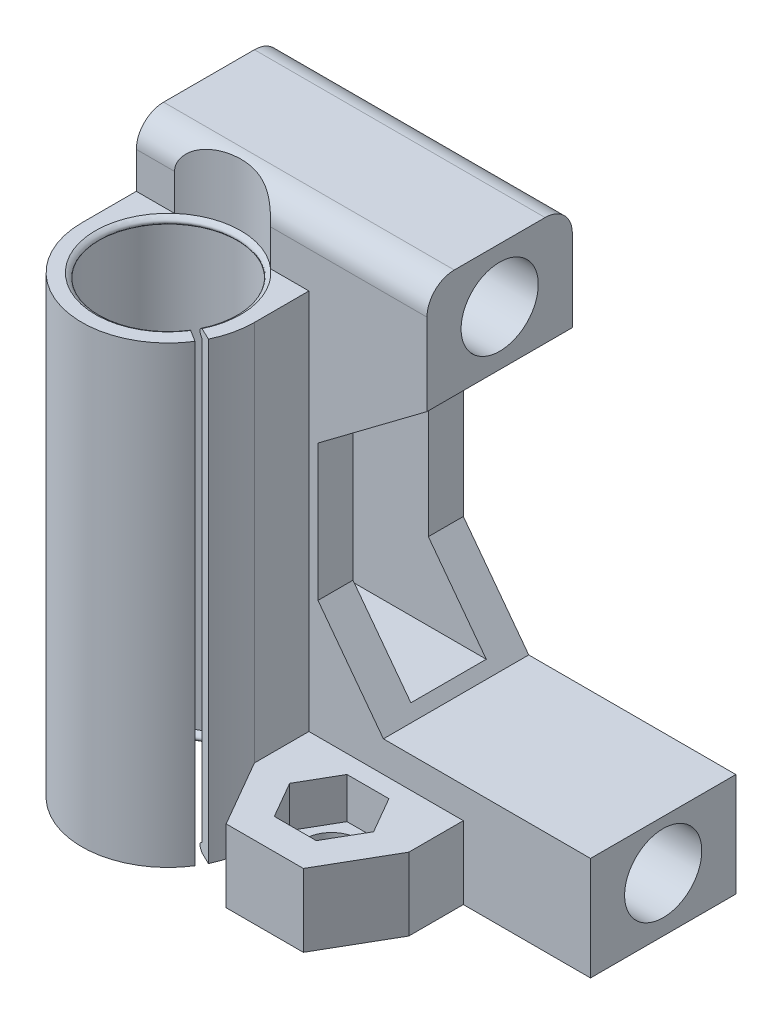
from build123d import *

# Parameters (mm, degrees)
BOSS_EXTRU_1_DEPTH           = 16
CONG_1_R                     = 3
ESQUISSE2_R                  = 4.25
ENL_V_MAT_EXTRU_1_DEPTH      = 78.491935064
BOSS_EXTRU_3_DEPTH           = 50
ENL_V_MAT_EXTRU_3_DEPTH      = 78.409624725
ENL_V_MAT_EXTRU_3_DEPTH_BACK = 78.409624725
BOSS_EXTRU_4_DEPTH           = 8
ENL_V_MAT_EXTRU_5_DEPTH      = 4.5
ESQUISSE10_R                 = 3
ENL_V_MAT_EXTRU_6_DEPTH      = 80.71511783


with BuildPart() as part:
    # Esquisse1 → Boss.-Extru.1 (new body)
    with BuildSketch(Plane.XY):
        Polygon((0, 0), (0, 57), (32, 57), (32, 45), (20, 36), (20, 21), (27.2, 11.4), (50, 11.4), (50, 0), align=None)
    extrude(amount=BOSS_EXTRU_1_DEPTH)

    # Congé1
    cong_1_edges = [part.edges().sort_by_distance(p)[0] for p in [
        (16, 57, 16),
        (16, 57, 0),
    ]]
    fillet(cong_1_edges, radius=CONG_1_R)

    # Esquisse2 → Enlèv. mat.-Extru.1 (cut, through all)
    with BuildSketch(Plane.ZY):
        with Locations((8, 51)):
            Circle(ESQUISSE2_R)
        with Locations((8, 6)):
            Circle(ESQUISSE2_R)
        Polygon((3.85, 42.5), (5.85, 44.5), (10.15, 44.5), (12.15, 42.5), (12.15, 12.5), (3.85, 12.5), align=None)
    extrude(amount=-ENL_V_MAT_EXTRU_1_DEPTH, mode=Mode.SUBTRACT)

    # Esquisse4 → Boss.-Extru.3 (add)
    with BuildSketch(Plane(origin=(0, 50, 0), x_dir=(1, 0, 0), z_dir=(0, 1, 0))):
        with BuildLine():
            Line((0, -22), (0, -16))
            Line((0, -16), (19, -16))
            Line((19, -16), (19, -22))
            ThreePointArc((19, -22), (9.5, -31.5), (0, -22))
        make_face()
    extrude(amount=-BOSS_EXTRU_3_DEPTH)

    # Esquisse3 → Enlèv. mat.-Extru.3 (cut, two sides)
    with BuildSketch(Plane(origin=(0, 50, 0), x_dir=(1, 0, 0), z_dir=(0, 1, 0))) as enl_v_mat_extru_3_sk:
        with BuildLine():
            Line((16.707123586, -25.472372332), (18.897371319, -26.527627668))
            Line((18.897371319, -26.527627668), (18.376515469, -27.608696206))
            Line((18.376515469, -27.608696206), (16.263059405, -26.273292348))
            ThreePointArc((16.263059405, -26.273292348), (2.5034386, -18.120808257), (16.707123586, -25.472372332))
        make_face()
    extrude(amount=ENL_V_MAT_EXTRU_3_DEPTH, mode=Mode.SUBTRACT)
    extrude(enl_v_mat_extru_3_sk.sketch, amount=-ENL_V_MAT_EXTRU_3_DEPTH_BACK, mode=Mode.SUBTRACT)

    # Esquisse7 → Boss.-Extru.4 (add)
    with BuildSketch(Plane.XZ):
        Polygon((31.75, 14.638784068), (36, 22), (31.75, 29.361215932), (23.25, 29.361215932), (19, 22), (23.25, 14.638784068), align=None)
        Polygon((36, 14.638784068), (36, 22), (31.75, 14.638784068), align=None)
        Polygon((19, 14.638784068), (23.25, 14.638784068), (19, 22), align=None)
    extrude(amount=-BOSS_EXTRU_4_DEPTH)

    # Esquisse8 → Enlèv. mat.-Extru.5 (cut)
    with BuildSketch(Plane(origin=(0, 8, 0), x_dir=(1, 0, 0), z_dir=(0, 1, 0))):
        Polygon((32.118802154, -22), (29.809401077, -18), (25.190598923, -18), (22.881197846, -22), (25.190598923, -26), (29.809401077, -26), align=None)
    extrude(amount=-ENL_V_MAT_EXTRU_5_DEPTH, mode=Mode.SUBTRACT)

    # Esquisse10 → Enlèv. mat.-Extru.6 (cut, through all)
    with BuildSketch(Plane(origin=(0, 3.5, 0), x_dir=(1, 0, 0), z_dir=(0, 1, 0))):
        with Locations(Location((27.5, -22, 0), (0, 0, 270))):
            Circle(ESQUISSE10_R)
    extrude(amount=-ENL_V_MAT_EXTRU_6_DEPTH, mode=Mode.SUBTRACT)

    # Balayage1: sweep along a curve in space
    with BuildLine() as balayage1_path:
        ThreePointArc((16.707123586, 0, 25.472372332), (2.5034386, 0, 18.120808257), (16.263059405, 0, 26.273292348))
    # Esquisse11 → Balayage1 (sweep)
    with BuildSketch(Plane(origin=(-7.22393592, 0, 11.432849379), x_dir=(-0.8453824255948864, 0, -0.5341615434447772), z_dir=(0.5341615434447772, 0, -0.8453824255948864))):
        with BuildLine():
            Line((-27.782686999, 50), (-27.782686999, 49))
            add(Edge.make_bspline(
                [(-27.782686999, 50), (-26.782686999, 49.5), (-27.782686999, 49)],
                knots=[0, 0, 0, 1, 1, 1], degree=2))
        make_face()
        with BuildLine():
            Line((-27.782686999, 0), (-27.782686999, 1))
            add(Edge.make_bspline(
                [(-27.782686999, 0), (-26.782686999, 0.5), (-27.782686999, 1)],
                knots=[0, 0, 0, 1, 1, 1], degree=2))
        make_face()
    sweep(path=balayage1_path.line)


solid = part.part
